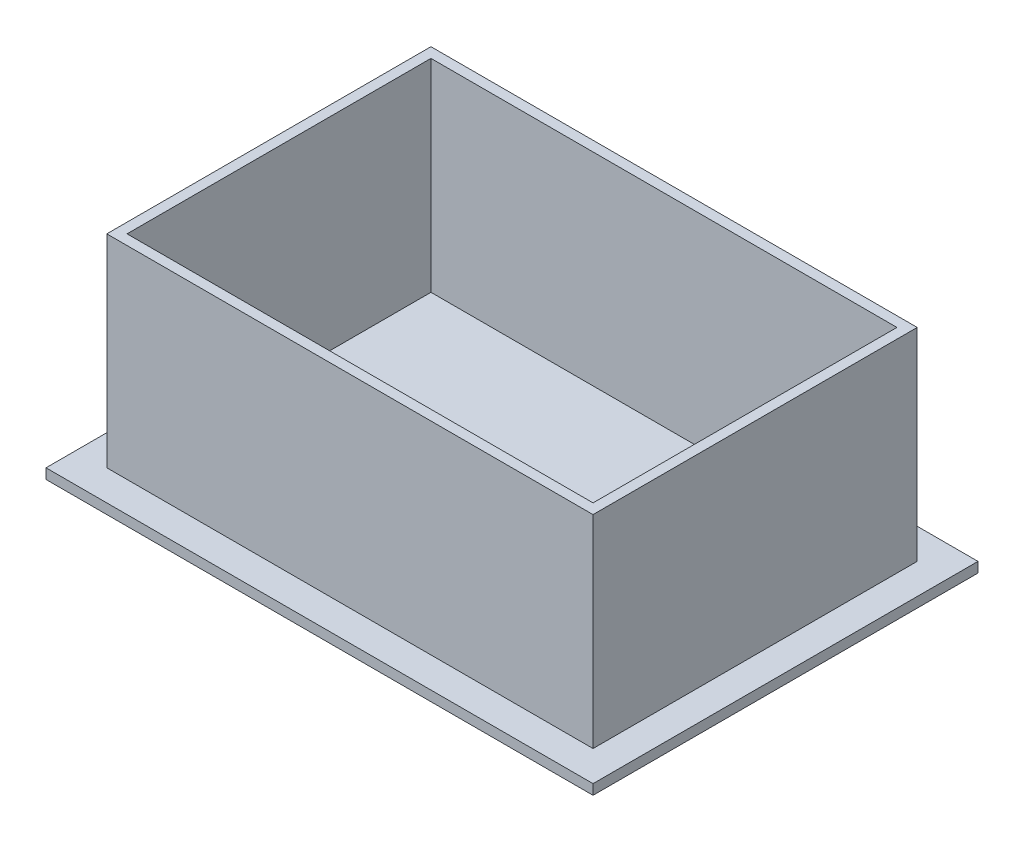
from build123d import *

# Parameters (mm, degrees)
SKETCH1_W           = 171.45
SKETCH1_H           = 120.65
BOSS_EXTRUDE1_DEPTH = 3.175
SKETCH2_W           = 152.4
SKETCH2_H           = 101.6
SKETCH2_W_2         = 146.05
SKETCH2_H_2         = 95.25
BOSS_EXTRUDE2_DEPTH = 63.5


with BuildPart() as part:
    # Sketch1 → Boss-Extrude1 (new body)
    with BuildSketch(Plane(origin=(0, 0, 0), x_dir=(1, 0, 0), z_dir=(0, 1, 0))):
        Rectangle(SKETCH1_W, SKETCH1_H)
    extrude(amount=BOSS_EXTRUDE1_DEPTH)

    # Sketch2 → Boss-Extrude2 (add)
    with BuildSketch(Plane(origin=(0, 3.175, 0), x_dir=(1, 0, 0), z_dir=(0, 1, 0))):
        Rectangle(SKETCH2_W, SKETCH2_H)
        Rectangle(SKETCH2_W_2, SKETCH2_H_2, mode=Mode.SUBTRACT)
    extrude(amount=BOSS_EXTRUDE2_DEPTH)


solid = part.part
